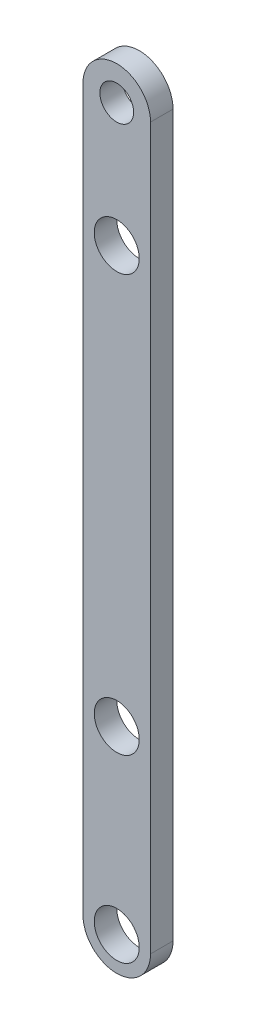
from build123d import *

# Parameters (mm, degrees)
SKETCH1_R           = 0.75
SKETCH1_R_2         = 1
BOSS_EXTRUDE1_DEPTH = 1


with BuildPart() as part:
    # Sketch1 → Boss-Extrude1 (new body)
    with BuildSketch(Plane.XY):
        with BuildLine():
            Line((1.5, 16), (1.5, -16))
            ThreePointArc((1.5, -16), (0, -17.5), (-1.5, -16))
            Line((-1.5, -16), (-1.5, 16))
            ThreePointArc((-1.5, 16), (0, 17.5), (1.5, 16))
        make_face()
        with Locations((0, 16)):
            Circle(SKETCH1_R, mode=Mode.SUBTRACT)
        with Locations((0, -16)):
            Circle(SKETCH1_R_2, mode=Mode.SUBTRACT)
        with Locations((0, 10.5)):
            Circle(SKETCH1_R_2, mode=Mode.SUBTRACT)
        with Locations((0, -8)):
            Circle(SKETCH1_R_2, mode=Mode.SUBTRACT)
    extrude(amount=BOSS_EXTRUDE1_DEPTH)


solid = part.part
